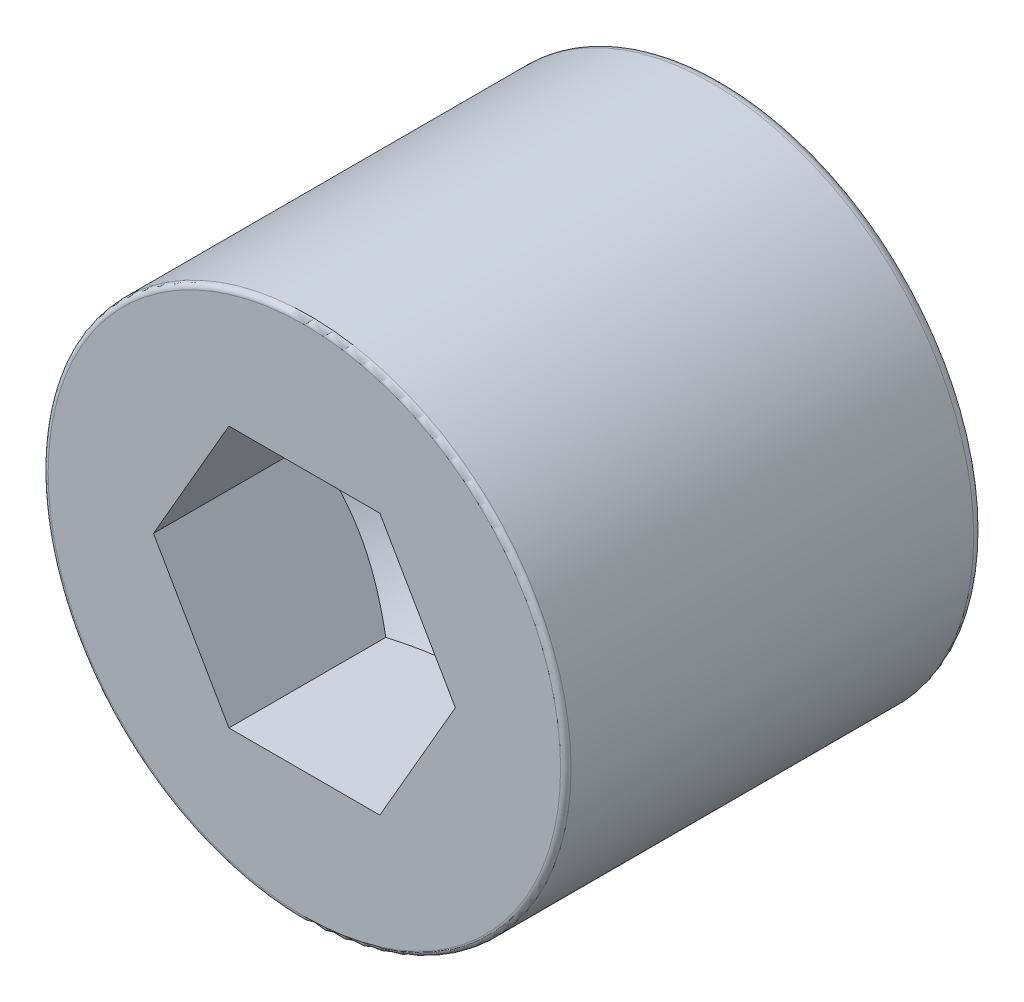
from build123d import *

# Parameters (mm, degrees)
SKIZZE1_R                       = 50
SKIZZE1_R_2                     = 9
AUFSATZ_LINEAR_AUSTRAGEN1_DEPTH = 80
VERRUNDUNG1_R                   = 2
VERRUNDUNG2_R                   = 1
AUFSATZ_LINEAR_AUSTRAGEN2_DEPTH = 30
SKIZZE12_OUTSIDE_W              = 134.496
SKIZZE12_OUTSIDE_H              = 134.496
SCHNITT_LINEAR_AUSTRAGEN3_DEPTH = 81


with BuildPart() as part:
    # Skizze1 → Aufsatz-Linear austragen1 (new body)
    with BuildSketch(Plane.XY):
        Circle(SKIZZE1_R)
        Circle(SKIZZE1_R_2, mode=Mode.SUBTRACT)
    extrude(amount=AUFSATZ_LINEAR_AUSTRAGEN1_DEPTH)

    # Verrundung1
    verrundung1_edges = [part.edges().sort_by_distance(p)[0] for p in [
        (-50, 0, 0),
        (-9, 0, 0),
    ]]
    fillet(verrundung1_edges, radius=VERRUNDUNG1_R)

    # Verrundung2
    verrundung2_edges = [part.edges().sort_by_distance(p)[0] for p in [
        (-50, 0, 80),
    ]]
    fillet(verrundung2_edges, radius=VERRUNDUNG2_R)


with BuildPart() as body_2:
    # Skizze2 → Aufsatz-Linear austragen2 (new body)
    with BuildSketch(Plane.XY.offset(80)):
        Polygon((28.867513459, 0), (14.43375673, 25), (-14.43375673, 25), (-28.867513459, 0), (-14.43375673, -25), (14.43375673, -25), align=None)
    extrude(amount=-AUFSATZ_LINEAR_AUSTRAGEN2_DEPTH)

    # Skizze10 → Rotation1 (revolve)
    with BuildSketch(Plane(origin=(-14.43375673, 0, 0), x_dir=(0, 0, 1), z_dir=(0, -1, 0)), mode=Mode.PRIVATE) as rotation1_sk:
        Polygon((50, 14.43375673), (33.333333333, -14.43375673), (50, -14.43375673), align=None)
    revolve(rotation1_sk.sketch.rotate(Axis((0, 0, 33.333333333), (0, 0, 1)), 180), axis=Axis((0, 0, 33.333333333), (0, 0, 1)))  # turned: the seam where the file's is

    # Skizze12 outside → Schnitt-Linear austragen3 (cut, through all)
    with BuildSketch(Plane.XY.offset(80)):
        Rectangle(SKIZZE12_OUTSIDE_W, SKIZZE12_OUTSIDE_H)
        Polygon((14.43375673, -25), (28.867513459, 0), (14.43375673, 25), (-14.43375673, 25), (-28.867513459, 0), (-14.43375673, -25), align=None, mode=Mode.SUBTRACT)
    extrude(amount=-SCHNITT_LINEAR_AUSTRAGEN3_DEPTH, mode=Mode.SUBTRACT)


with BuildPart() as part_1:
    add(part.part)

    # Kombinieren1: cut body 2
    add(body_2.part, mode=Mode.SUBTRACT)


solid = part_1.part
